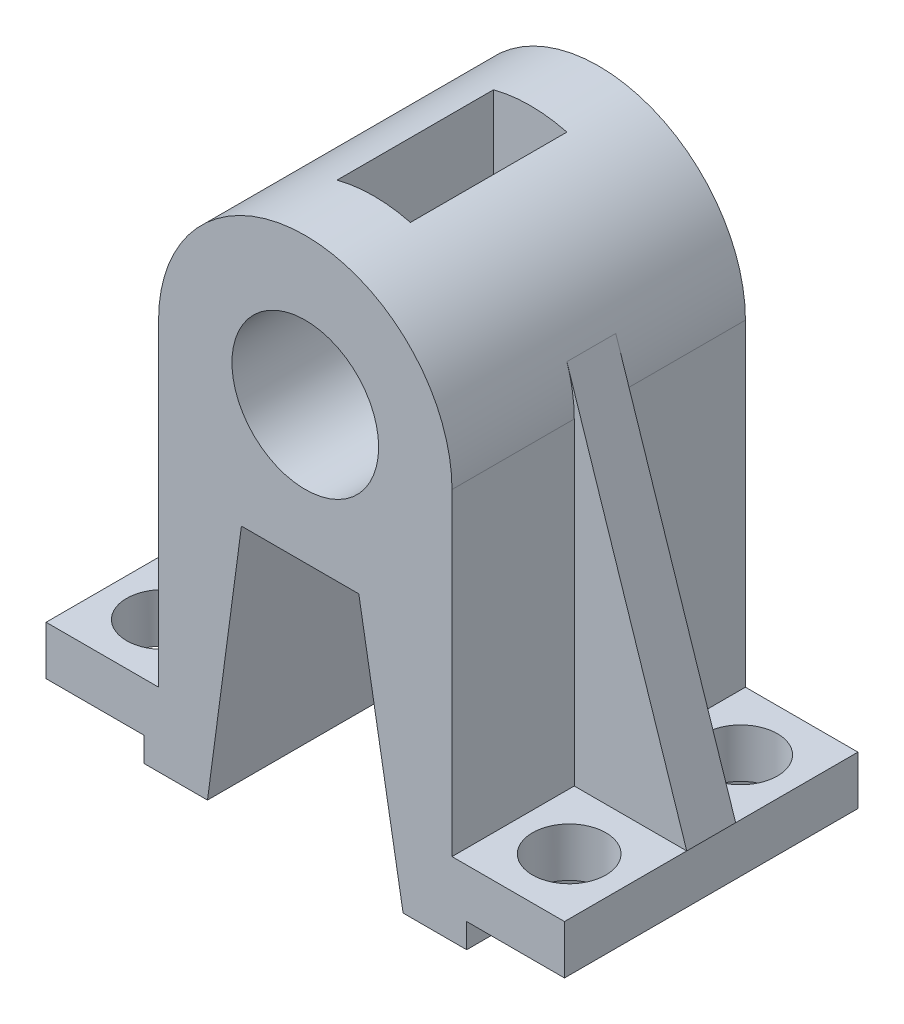
from build123d import *

# Parameters (mm, degrees)
SKETCH1_R           = 15
BOSS_EXTRUDE1_DEPTH = 30
SKETCH2_R           = 7.5
CUT_EXTRUDE1_DEPTH  = 60
SKETCH3_W           = 15
SKETCH3_H           = 32
CUT_EXTRUDE2_DEPTH  = 101.543522914
RIB1_REACH          = 102.544
SKETCH4_WALL_W      = 281.406902826
SKETCH4_WALL_H      = 10


with BuildPart() as part:
    # Sketch1 → Boss-Extrude1 (new, symmetric)
    with BuildSketch(Plane.XY):
        with BuildLine():
            Line((30, 0), (30, -65))
            Line((30, -65), (53, -65))
            Line((53, -65), (53, -75))
            Line((53, -75), (33, -75))
            Line((33, -75), (33, -80))
            Line((33, -80), (20, -80))
            Line((20, -80), (10.9437787, -28))
            Line((10.9437787, -28), (-13.0562213, -28))
            Line((-13.0562213, -28), (-20, -80))
            Line((-20, -80), (-33, -80))
            Line((-33, -80), (-33, -75))
            Line((-33, -75), (-53, -75))
            Line((-53, -75), (-53, -65))
            Line((-53, -65), (-30, -65))
            Line((-30, -65), (-30, 0))
            ThreePointArc((-30, 0), (0, 30), (30, 0))
        make_face()
        Circle(SKETCH1_R, mode=Mode.SUBTRACT)
    extrude(amount=BOSS_EXTRUDE1_DEPTH, both=True)

    # Sketch2 → Cut-Extrude1 (cut)
    with BuildSketch(Plane(origin=(0, -65, 0), x_dir=(1, 0, 0), z_dir=(0, 1, 0))):
        with Locations(Location((41.5, 17.538074841, 0), (0, 0, 270))):
            Circle(SKETCH2_R)
        with Locations((41.5, -17.538074841)):
            Circle(SKETCH2_R)
    cut_extrude1 = extrude(amount=-CUT_EXTRUDE1_DEPTH, mode=Mode.SUBTRACT)

    # Mirror1: Cut-Extrude1 across plane
    add(cut_extrude1.mirror(Plane(origin=(0, 0, 0), x_dir=(0, 0, 1), z_dir=(1, 0, 0))), mode=Mode.SUBTRACT)

    # Sketch3 → Cut-Extrude2 (cut, through all)
    with BuildSketch(Plane(origin=(0, 0, 0), x_dir=(1, 0, 0), z_dir=(0, 1, 0))):
        Rectangle(SKETCH3_W, SKETCH3_H)
    extrude(amount=CUT_EXTRUDE2_DEPTH, mode=Mode.SUBTRACT)

    # Sketch4 wall → Rib1 (add, up to next)
    with BuildSketch(Plane(origin=(-40.746781429, -27.806470527, 0), x_dir=(-0.312901964861, -0.949785428603, 0), z_dir=(0.949785428603, -0.312901964861, 0)), mode=Mode.PRIVATE) as rib1_sk1:
        Rectangle(SKETCH4_WALL_W, SKETCH4_WALL_H)
    rib1_tool1 = extrude(rib1_sk1.sketch, amount=RIB1_REACH, mode=Mode.PRIVATE) - part.part
    rib1 = rib1_tool1.solids().sort_by_distance((-40.746781429, -27.806470527, 0))[0]
    add(rib1)

    # Mirror2: Rib1 across plane
    add(rib1.mirror(Plane(origin=(0, 0, 0), x_dir=(0, 0, 1), z_dir=(1, 0, 0))))


solid = part.part
